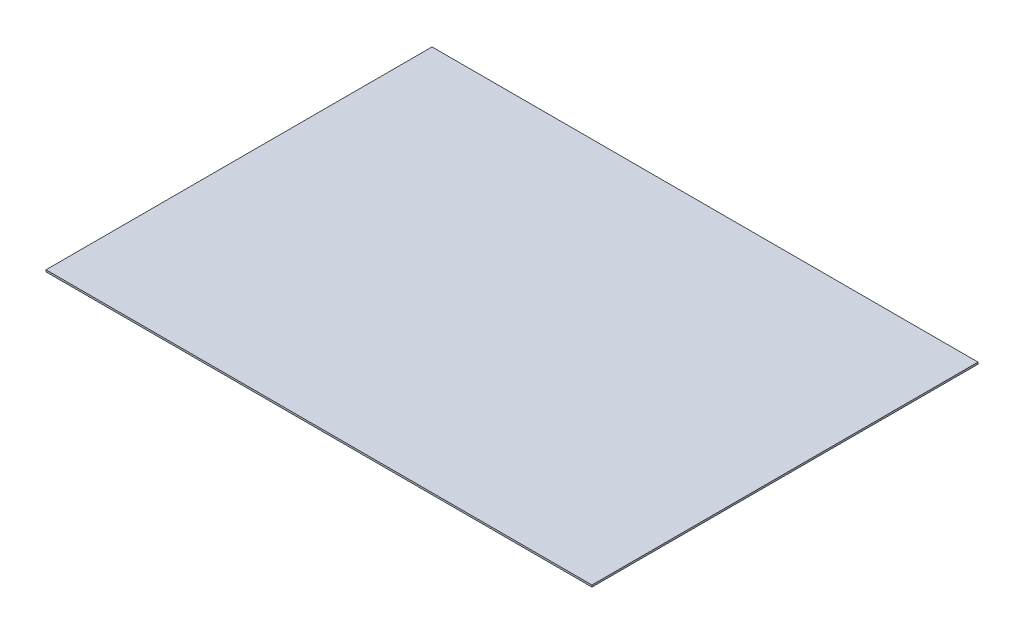
from build123d import *

# Parameters (mm, degrees)
SKETCH1_W           = 297
SKETCH1_H           = 210
BOSS_EXTRUDE1_DEPTH = 1


with BuildPart() as part:
    # Sketch1 → Boss-Extrude1 (new body)
    with BuildSketch(Plane(origin=(0, 0, 0), x_dir=(1, 0, 0), z_dir=(0, 1, 0))):
        with Locations((-3.942477876, -11.913716814)):
            Rectangle(SKETCH1_W, SKETCH1_H)
    extrude(amount=BOSS_EXTRUDE1_DEPTH)


solid = part.part
